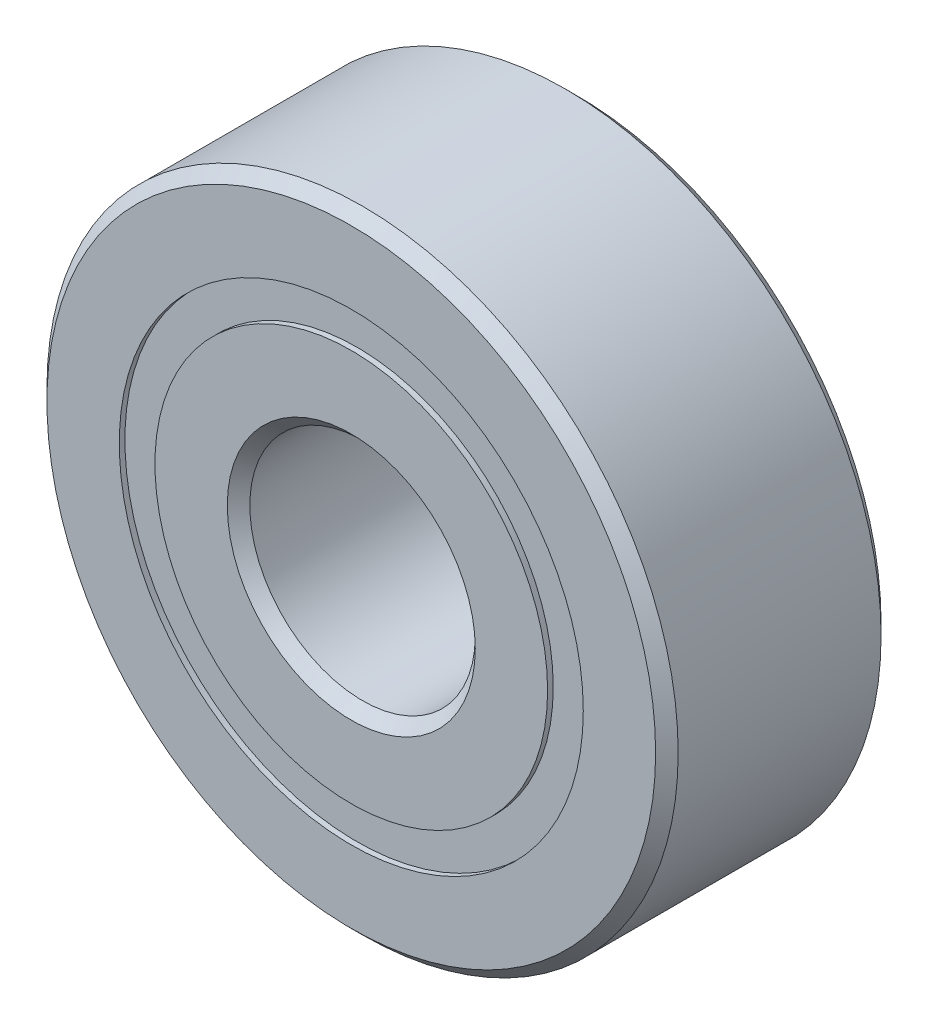
from build123d import *

# Parameters (mm, degrees)
CIRPATTERN1_COUNT = 12
SKETCH5_W         = 1.195563381
SKETCH5_H         = 0.791208792


with BuildPart() as part:
    # Sketch1 → Revolve1 (revolve)
    with BuildSketch(Plane(origin=(0, 0, 0), x_dir=(0, 0, -1), z_dir=(1, 0, 0))):
        with BuildLine():
            Line((2.25, 7), (-2.25, 7))
            Line((-2.25, 7), (-2.5, 6.75))
            Line((-2.5, 6.75), (-2.5, 5.145604396))
            Line((-2.5, 5.145604396), (-1.111111111, 5.145604396))
            ThreePointArc((-1.111111111, 5.145604396), (0, 5.929436619), (1.111111111, 5.145604396))
            Line((1.111111111, 5.145604396), (2.5, 5.145604396))
            Line((2.5, 5.145604396), (2.5, 6.75))
            Line((2.5, 6.75), (2.25, 7))
        make_face()
    revolve(axis=Axis((0, 0, 2.5), (0, 0, -1)))


with BuildPart() as body_2:
    # Sketch3 → Revolve3 (revolve)
    with BuildSketch(Plane(origin=(0, 0, 0), x_dir=(0, 0, -1), z_dir=(1, 0, 0))):
        with BuildLine():
            Line((-2.5, 4.354395604), (-1.111111111, 4.354395604))
            ThreePointArc((-1.111111111, 4.354395604), (0, 3.570563381), (1.111111111, 4.354395604))
            Line((1.111111111, 4.354395604), (2.5, 4.354395604))
            Line((2.5, 4.354395604), (2.5, 2.75))
            Line((2.5, 2.75), (2.25, 2.5))
            Line((2.25, 2.5), (-2.25, 2.5))
            Line((-2.25, 2.5), (-2.5, 2.75))
            Line((-2.5, 2.75), (-2.5, 4.354395604))
        make_face()
    revolve(axis=Axis((0, 0, 2.5), (0, 0, -1)))


with BuildPart() as body_3:
    # Sketch4 → Revolve4 (revolve)
    with BuildSketch(Plane(origin=(0, 0, 0), x_dir=(0, 0, -1), z_dir=(1, 0, 0))):
        with BuildLine():
            Line((-1.179436619, 4.75), (1.179436619, 4.75))
            ThreePointArc((1.179436619, 4.75), (0, 5.929436619), (-1.179436619, 4.75))
        make_face()
    revolve(axis=Axis((0, 4.75, 1.179436619), (0, 0, -1)))


with BuildPart() as cirpattern1_1:
    # CirPattern1: pattern copy
    add(body_3.part.rotate(Axis((0, 0, -2.5), (0, 0, 1)), 1 * 360 / CIRPATTERN1_COUNT))


with BuildPart() as cirpattern1_2:
    # CirPattern1: pattern copy
    add(body_3.part.rotate(Axis((0, 0, -2.5), (0, 0, 1)), 2 * 360 / CIRPATTERN1_COUNT))


with BuildPart() as cirpattern1_3:
    # CirPattern1: pattern copy
    add(body_3.part.rotate(Axis((0, 0, -2.5), (0, 0, 1)), 3 * 360 / CIRPATTERN1_COUNT))


with BuildPart() as cirpattern1_4:
    # CirPattern1: pattern copy
    add(body_3.part.rotate(Axis((0, 0, -2.5), (0, 0, 1)), 4 * 360 / CIRPATTERN1_COUNT))


with BuildPart() as cirpattern1_5:
    # CirPattern1: pattern copy
    add(body_3.part.rotate(Axis((0, 0, -2.5), (0, 0, 1)), 5 * 360 / CIRPATTERN1_COUNT))


with BuildPart() as cirpattern1_6:
    # CirPattern1: pattern copy
    add(body_3.part.rotate(Axis((0, 0, -2.5), (0, 0, 1)), 6 * 360 / CIRPATTERN1_COUNT))


with BuildPart() as cirpattern1_7:
    # CirPattern1: pattern copy
    add(body_3.part.rotate(Axis((0, 0, -2.5), (0, 0, 1)), 7 * 360 / CIRPATTERN1_COUNT))


with BuildPart() as cirpattern1_8:
    # CirPattern1: pattern copy
    add(body_3.part.rotate(Axis((0, 0, -2.5), (0, 0, 1)), 8 * 360 / CIRPATTERN1_COUNT))


with BuildPart() as cirpattern1_9:
    # CirPattern1: pattern copy
    add(body_3.part.rotate(Axis((0, 0, -2.5), (0, 0, 1)), 9 * 360 / CIRPATTERN1_COUNT))


with BuildPart() as cirpattern1_10:
    # CirPattern1: pattern copy
    add(body_3.part.rotate(Axis((0, 0, -2.5), (0, 0, 1)), 10 * 360 / CIRPATTERN1_COUNT))


with BuildPart() as cirpattern1_11:
    # CirPattern1: pattern copy
    add(body_3.part.rotate(Axis((0, 0, -2.5), (0, 0, 1)), 11 * 360 / CIRPATTERN1_COUNT))


with BuildPart() as body_15:
    # Sketch5 → Revolve5 (revolve)
    with BuildSketch(Plane(origin=(0, 0, 0), x_dir=(0, 0, -1), z_dir=(1, 0, 0))):
        with Locations((-1.77721831, 4.75)):
            Rectangle(SKETCH5_W, SKETCH5_H)
        with Locations((1.77721831, 4.75)):
            Rectangle(SKETCH5_W, SKETCH5_H)
    revolve(axis=Axis((0, 0, 2.5), (0, 0, -1)))


solid = Compound([part.part, body_2.part, body_3.part, cirpattern1_1.part, cirpattern1_2.part, cirpattern1_3.part, cirpattern1_4.part, cirpattern1_5.part, cirpattern1_6.part, cirpattern1_7.part, cirpattern1_8.part, cirpattern1_9.part, cirpattern1_10.part, cirpattern1_11.part, body_15.part])
